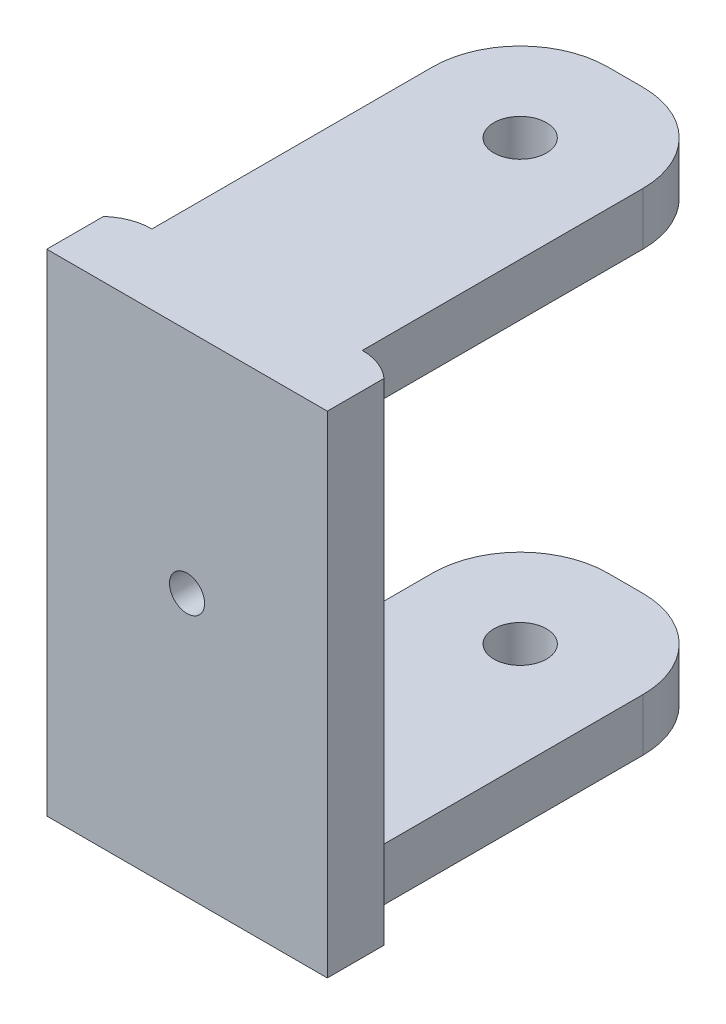
from build123d import *

# Parameters (mm, degrees)
EXTRUDE_2_DEPTH     = 14
SKETCH_4_R          = 1.5
CUT_EXTRUDE_2_DEPTH = 21
EXTRUDE_3_DEPTH     = 14
SKETCH_5_W          = 12
SKETCH_5_H          = 26.808765345
CUT_EXTRUDE_3_DEPTH = 11
SKETCH_7_R          = 1
CUT_EXTRUDE_4_DEPTH = 11
SKETCH_8_R          = 2
CUT_EXTRUDE_5_DEPTH = 1
SKETCH_9_W          = 1
SKETCH_9_H          = 28
CUT_EXTRUDE_6_DEPTH = 10


with BuildPart() as part:
    # 草图1 → 凸台-拉伸2 (new body, symmetric)
    with BuildSketch(Plane(origin=(0, 0, 0), x_dir=(1, 0, 0), z_dir=(0, 1, 0))):
        with BuildLine():
            Line((-5.026135275, 12.870728162), (-3.026135275, 12.870728162))
            ThreePointArc((-3.026135275, 12.870728162), (0.50939863, 11.406262068), (1.973864725, 7.870728162))
            Line((1.973864725, 7.870728162), (1.973864725, -8.129271838))
            Line((1.973864725, -8.129271838), (-10.026135275, -8.129271838))
            Line((-10.026135275, -8.129271838), (-10.026135275, 7.870728162))
            ThreePointArc((-10.026135275, 7.870728162), (-8.561669181, 11.406262068), (-5.026135275, 12.870728162))
        make_face()
    extrude(amount=EXTRUDE_2_DEPTH, both=True)

    # 草图4 → 切除-拉伸2 (cut, symmetric)
    with BuildSketch(Plane(origin=(0, 0, 0), x_dir=(1, 0, 0), z_dir=(0, 1, 0))):
        with Locations((-4.026135275, 6.870728162)):
            Circle(SKETCH_4_R)
    extrude(amount=CUT_EXTRUDE_2_DEPTH, both=True, mode=Mode.SUBTRACT)

    # 草图2 → 凸台-拉伸3 (add, symmetric)
    with BuildSketch(Plane(origin=(0, 0, 0), x_dir=(1, 0, 0), z_dir=(0, 1, 0))):
        with BuildLine():
            Line((-10.026135275, -8.129271838), (1.973864725, -8.129271838))
            ThreePointArc((1.973864725, -8.129271838), (4.095185068, -9.007951494), (4.973864725, -11.129271838))
            Line((4.973864725, -11.129271838), (4.973864725, -12.129271838))
            Line((4.973864725, -12.129271838), (-13.026135275, -12.129271838))
            Line((-13.026135275, -12.129271838), (-13.026135275, -11.129271838))
            ThreePointArc((-13.026135275, -11.129271838), (-12.147455619, -9.007951494), (-10.026135275, -8.129271838))
        make_face()
    extrude(amount=EXTRUDE_3_DEPTH, both=True)

    # 草图5 → 切除-拉伸3 (cut, symmetric)
    with BuildSketch(Plane(origin=(0, 0, 0), x_dir=(1, 0, 0), z_dir=(0, 1, 0))):
        with Locations((-4.026135275, 5.275110834)):
            Rectangle(SKETCH_5_W, SKETCH_5_H)
    extrude(amount=CUT_EXTRUDE_3_DEPTH, both=True, mode=Mode.SUBTRACT)

    # 草图7 → 切除-拉伸4 (cut, symmetric)
    with BuildSketch(Plane.XY.offset(12.129271838)):
        with Locations((-4.026135275, 1)):
            Circle(SKETCH_7_R)
    extrude(amount=CUT_EXTRUDE_4_DEPTH, both=True, mode=Mode.SUBTRACT)

    # 草图8 → 切除-拉伸5 (cut)
    with BuildSketch(Plane(origin=(0, 0, 8.129271838), x_dir=(-1, 0, 0), z_dir=(0, 0, -1))):
        with Locations((4.026135275, 1)):
            Circle(SKETCH_8_R)
    extrude(amount=-CUT_EXTRUDE_5_DEPTH, mode=Mode.SUBTRACT)

    # 草图9 → 切除-拉伸6 (cut)
    with BuildSketch(Plane.XY.offset(12.129271838)):
        with Locations((-12.526135275, 0)):
            Rectangle(SKETCH_9_W, SKETCH_9_H)
        with Locations((4.473864725, 0)):
            Rectangle(SKETCH_9_W, SKETCH_9_H)
    extrude(amount=-CUT_EXTRUDE_6_DEPTH, mode=Mode.SUBTRACT)


solid = part.part
